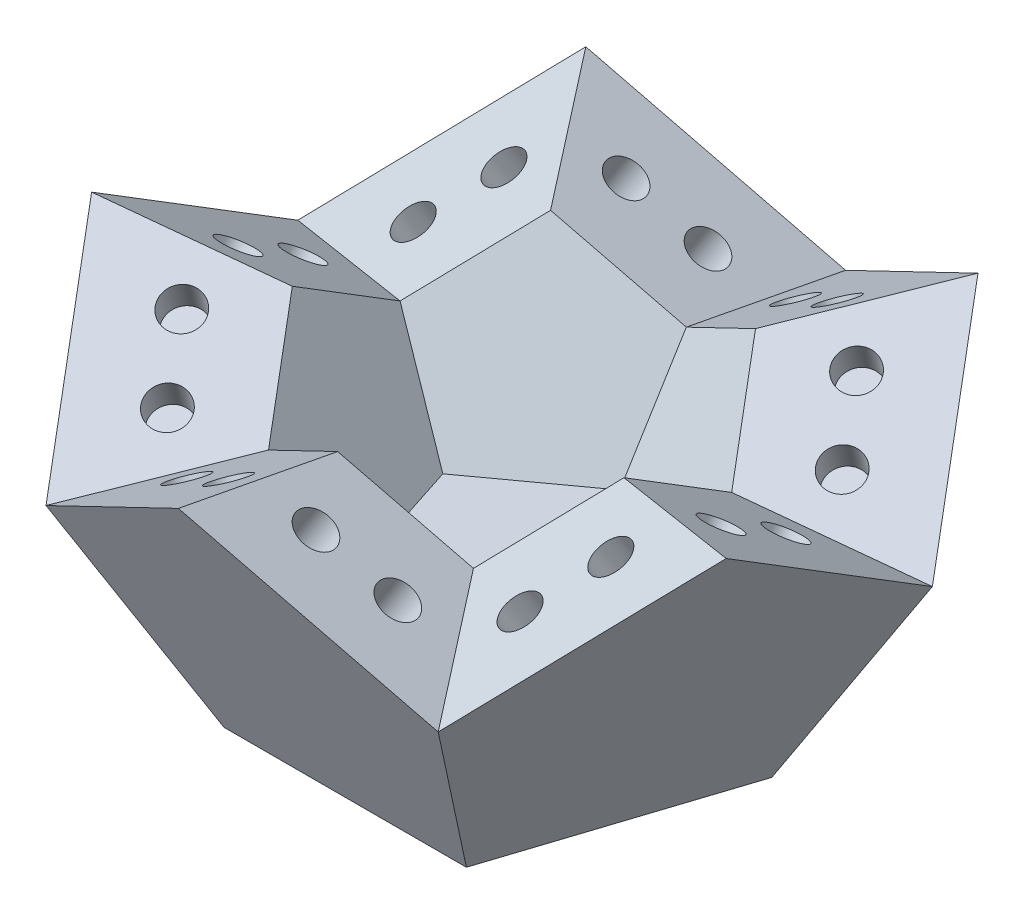
from build123d import *
from build123d.topology import SkipClean

# Parameters (mm, degrees)
BOSS_EXTRUDE1_DEPTH     = 6.752040791
BOSS_EXTRUDE1_TAPER     = 31.717474411
SKETCH3_R               = 1
CUT_EXTRUDE1_DEPTH      = 2
CIRPATTERN1_COUNT       = 5
MIRROR1_COPY_1_SKETCH_R = 1
MIRROR1_COPY_1_DEPTH    = 2
MIRROR1_COPY_2_SKETCH_R = 1
MIRROR1_COPY_2_DEPTH    = 2
MIRROR1_COPY_3_SKETCH_R = 1
MIRROR1_COPY_3_DEPTH    = 2
MIRROR1_COPY_4_SKETCH_R = 1
MIRROR1_COPY_4_DEPTH    = 2
MIRROR2_COPY_1_SKETCH_R = 1
MIRROR2_COPY_1_DEPTH    = 2
MIRROR2_COPY_2_SKETCH_R = 1
MIRROR2_COPY_2_DEPTH    = 2
MIRROR2_COPY_3_SKETCH_R = 1
MIRROR2_COPY_3_DEPTH    = 2
MIRROR2_COPY_4_SKETCH_R = 1
MIRROR2_COPY_4_DEPTH    = 2
MIRROR3_COPY_1_SKETCH_R = 1
MIRROR3_COPY_1_DEPTH    = 2
MIRROR3_COPY_2_SKETCH_R = 1
MIRROR3_COPY_2_DEPTH    = 2
MIRROR3_COPY_3_SKETCH_R = 1
MIRROR3_COPY_3_DEPTH    = 2
MIRROR3_COPY_4_SKETCH_R = 1
MIRROR3_COPY_4_DEPTH    = 2
MIRROR4_COPY_1_SKETCH_R = 1
MIRROR4_COPY_1_DEPTH    = 2
MIRROR4_COPY_2_SKETCH_R = 1
MIRROR4_COPY_2_DEPTH    = 2
MIRROR4_COPY_3_SKETCH_R = 1
MIRROR4_COPY_3_DEPTH    = 2
MIRROR4_COPY_4_SKETCH_R = 1
MIRROR4_COPY_4_DEPTH    = 2
MIRROR5_COPY_1_SKETCH_R = 1
MIRROR5_COPY_1_DEPTH    = 2
MIRROR5_COPY_2_SKETCH_R = 1
MIRROR5_COPY_2_DEPTH    = 2
MIRROR5_COPY_3_SKETCH_R = 1
MIRROR5_COPY_3_DEPTH    = 2
MIRROR5_COPY_4_SKETCH_R = 1
MIRROR5_COPY_4_DEPTH    = 2


with BuildPart() as part:
    # Sketch1 → Boss-Extrude1 (new body)
    with BuildSketch(Plane(origin=(0, 0, 0), x_dir=(1, 0, 0), z_dir=(0, 1, 0))):
        Polygon((0, 10.803265266), (-10.274515829, 3.338392562), (-6.35, -8.740025195), (6.35, -8.740025195), (10.274515829, 3.338392562), align=None)
    boss_extrude1 = extrude(amount=BOSS_EXTRUDE1_DEPTH, taper=BOSS_EXTRUDE1_TAPER)

    # Sketch3 → Cut-Extrude1 (cut)
    with BuildSketch(Plane(origin=(0, 3.908658092, 6.324341644), x_dir=(1, 0, 0), z_dir=(1.6266940928737823e-15, 0.5257311121191348, 0.8506508083520392))):
        with Locations((-2, -0.626153166)):
            Circle(SKETCH3_R)
        with Locations((2, -0.626153166)):
            Circle(SKETCH3_R)
    cut_extrude1 = extrude(amount=-CUT_EXTRUDE1_DEPTH, mode=Mode.SUBTRACT)

    # CirPattern1: Cut-Extrude1 ×5 about axis
    cirpattern1_axis = Axis((0, 14.848740719, 0), (0, -1, 0))
    for i in range(1, CIRPATTERN1_COUNT):
        add(cut_extrude1.rotate(cirpattern1_axis, i * 360 / CIRPATTERN1_COUNT), mode=Mode.SUBTRACT)

    # Mirror1: Boss-Extrude1, Cut-Extrude1 across plane
    add(boss_extrude1.mirror(Plane(origin=(0, 0, -10.803265266), x_dir=(-0.4742680099309791, 0.49867489660708403, 0.7255296012224607), z_dir=(-0.5000000000000008, 0.5257311121191346, -0.6881909602355855))))
    add(cut_extrude1.mirror(Plane(origin=(0, 0, -10.803265266), x_dir=(-0.4742680099309791, 0.49867489660708403, 0.7255296012224607), z_dir=(-0.5000000000000008, 0.5257311121191346, -0.6881909602355855))), mode=Mode.SUBTRACT)

    # Mirror1 copy 1 sketch → Mirror1 copy 1 (cut)
    with BuildSketch(Plane(origin=(-9.73216108, 7.817316184, -3.162170822), x_dir=(-0.4999999999999997, 0.8506508083520404, -0.16245984811645123), z_dir=(-0.30901699437494484, 0, 0.9510565162951544))):
        with Locations((-2, 0.626153166)):
            Circle(MIRROR1_COPY_1_SKETCH_R)
        with Locations((2, 0.626153166)):
            Circle(MIRROR1_COPY_1_SKETCH_R)
    extrude(amount=-MIRROR1_COPY_1_DEPTH, mode=Mode.SUBTRACT)

    # Mirror1 copy 2 sketch → Mirror1 copy 2 (cut)
    with BuildSketch(Plane(origin=(-3.717354749, 3.908658092, -5.116499868), x_dir=(-0.8090169943749469, 0, 0.587785252292474), z_dir=(0.5000000000000007, -0.5257311121191344, 0.6881909602355858))):
        with Locations((-2, 0.626153166)):
            Circle(MIRROR1_COPY_2_SKETCH_R)
        with Locations((2, 0.626153166)):
            Circle(MIRROR1_COPY_2_SKETCH_R)
    extrude(amount=-MIRROR1_COPY_2_DEPTH, mode=Mode.SUBTRACT)

    # Mirror1 copy 3 sketch → Mirror1 copy 3 (cut)
    with BuildSketch(Plane(origin=(0, 7.817316184, -10.232999736), x_dir=(0, -0.8506508083520413, 0.5257311121191314), z_dir=(1, 0, 0))):
        with Locations((-2, 0.626153166)):
            Circle(MIRROR1_COPY_3_SKETCH_R)
        with Locations((2, 0.626153166)):
            Circle(MIRROR1_COPY_3_SKETCH_R)
    extrude(amount=-MIRROR1_COPY_3_DEPTH, mode=Mode.SUBTRACT)

    # Mirror1 copy 4 sketch → Mirror1 copy 4 (cut)
    with BuildSketch(Plane(origin=(-3.717354749, 14.141657828, -11.440841512), x_dir=(0.809016994374946, -0.5257311121191345, -0.2628655560595698), z_dir=(0.5000000000000017, 0.8506508083520392, -0.16245984811645123))):
        with Locations((-2, 0.626153166)):
            Circle(MIRROR1_COPY_4_SKETCH_R)
        with Locations((2, 0.626153166)):
            Circle(MIRROR1_COPY_4_SKETCH_R)
    extrude(amount=-MIRROR1_COPY_4_DEPTH, mode=Mode.SUBTRACT)

    # Mirror2: Boss-Extrude1, Cut-Extrude1 across plane
    add(boss_extrude1.mirror(Plane(origin=(-10.274515829, 0, -3.338392562), x_dir=(0.22041412184245582, -0.14323377902898754, 0.9648324722134378), z_dir=(-0.8090169943749466, 0.5257311121191346, 0.2628655560595678))))
    add(cut_extrude1.mirror(Plane(origin=(-10.274515829, 0, -3.338392562), x_dir=(0.22041412184245582, -0.14323377902898754, 0.9648324722134378), z_dir=(-0.8090169943749466, 0.5257311121191346, 0.2628655560595678))), mode=Mode.SUBTRACT)

    # Mirror2 copy 1 sketch → Mirror2 copy 1 (cut)
    with BuildSketch(Plane(origin=(-6.014806331, 3.908658092, 1.954329046), x_dir=(0.309016994374948, 0, 0.9510565162951534), z_dir=(0.8090169943749471, -0.5257311121191345, -0.26286555605956746))):
        with Locations((-2, 0.626153166)):
            Circle(MIRROR2_COPY_1_SKETCH_R)
        with Locations((2, 0.626153166)):
            Circle(MIRROR2_COPY_1_SKETCH_R)
    extrude(amount=-MIRROR2_COPY_1_DEPTH, mode=Mode.SUBTRACT)

    # Mirror2 copy 2 sketch → Mirror2 copy 2 (cut)
    with BuildSketch(Plane(origin=(-9.73216108, 7.817316184, -3.162170822), x_dir=(0.4999999999999979, -0.8506508083520414, 0.16245984811645336), z_dir=(0.3090169943749476, -1.1061928888882846e-15, -0.9510565162951538))):
        with Locations((-2, 0.626153166)):
            Circle(MIRROR2_COPY_2_SKETCH_R)
        with Locations((2, 0.626153166)):
            Circle(MIRROR2_COPY_2_SKETCH_R)
    extrude(amount=-MIRROR2_COPY_2_DEPTH, mode=Mode.SUBTRACT)

    # Mirror2 copy 3 sketch → Mirror2 copy 3 (cut)
    with BuildSketch(Plane(origin=(-12.029612663, 14.141657828, 0), x_dir=(-2.8865798640254106e-15, -0.5257311121191347, -0.8506508083520393), z_dir=(2.4424906541753397e-15, 0.8506508083520393, -0.5257311121191347))):
        with Locations((-2, 0.626153166)):
            Circle(MIRROR2_COPY_3_SKETCH_R)
        with Locations((2, 0.626153166)):
            Circle(MIRROR2_COPY_3_SKETCH_R)
    extrude(amount=-MIRROR2_COPY_3_DEPTH, mode=Mode.SUBTRACT)

    # Mirror2 copy 4 sketch → Mirror2 copy 4 (cut)
    with BuildSketch(Plane(origin=(-9.73216108, 14.141657828, 7.070828914), x_dir=(-0.5000000000000008, 0.5257311121191339, -0.6881909602355862), z_dir=(0.30901699437495067, 0.85065080835204, 0.4253254041760177))):
        with Locations((-2, 0.626153166)):
            Circle(MIRROR2_COPY_4_SKETCH_R)
        with Locations((2, 0.626153166)):
            Circle(MIRROR2_COPY_4_SKETCH_R)
    extrude(amount=-MIRROR2_COPY_4_DEPTH, mode=Mode.SUBTRACT)

    # Mirror3: Boss-Extrude1, Cut-Extrude1 across plane
    add(boss_extrude1.mirror(Plane(origin=(-6.35, 0, 8.740025195), x_dir=(-2.6320463315684497e-15, -0.8506508083520393, 0.5257311121191345), z_dir=(1.6266940928737817e-15, 0.5257311121191347, 0.8506508083520393))))
    add(cut_extrude1.mirror(Plane(origin=(-6.35, 0, 8.740025195), x_dir=(-2.6320463315684497e-15, -0.8506508083520393, 0.5257311121191345), z_dir=(1.6266940928737817e-15, 0.5257311121191347, 0.8506508083520393))), mode=Mode.SUBTRACT)

    # Mirror3 copy 1 sketch → Mirror3 copy 1 (cut)
    with SkipClean():  # the faces are left unmerged after this step: merging them gives an invalid solid
        with BuildSketch(Plane(origin=(-6.014806331, 7.817316184, 8.27867069), x_dir=(0.3090169943749462, -0.8506508083520415, -0.4253254041760179), z_dir=(-0.8090169943749479, 0, -0.5877852522924727))):
            with Locations((-2, 0.626153166)):
                Circle(MIRROR3_COPY_1_SKETCH_R)
            with Locations((2, 0.626153166)):
                Circle(MIRROR3_COPY_1_SKETCH_R)
        extrude(amount=-MIRROR3_COPY_1_DEPTH, mode=Mode.SUBTRACT)

    # Mirror3 copy 2 sketch → Mirror3 copy 2 (cut)
    with SkipClean():  # the faces are left unmerged after this step: merging them gives an invalid solid
        with BuildSketch(Plane(origin=(-3.717354749, 14.141657828, 11.440841512), x_dir=(-0.8090169943749482, -0.5257311121191344, -0.26286555605956313), z_dir=(-0.5, 0.8506508083520394, -0.1624598481164556))):
            with Locations((-2, 0.626153166)):
                Circle(MIRROR3_COPY_2_SKETCH_R)
            with Locations((2, 0.626153166)):
                Circle(MIRROR3_COPY_2_SKETCH_R)
        extrude(amount=-MIRROR3_COPY_2_DEPTH, mode=Mode.SUBTRACT)

    # Mirror3 copy 3 sketch → Mirror3 copy 3 (cut)
    with SkipClean():  # the faces are left unmerged after this step: merging them gives an invalid solid
        with BuildSketch(Plane(origin=(3.717354749, 14.141657828, 11.440841512), x_dir=(-0.8090169943749467, 0.5257311121191343, 0.262865556059568), z_dir=(0.4999999999999991, 0.8506508083520395, -0.16245984811645744))):
            with Locations((-2, 0.626153166)):
                Circle(MIRROR3_COPY_3_SKETCH_R)
            with Locations((2, 0.626153166)):
                Circle(MIRROR3_COPY_3_SKETCH_R)
        extrude(amount=-MIRROR3_COPY_3_DEPTH, mode=Mode.SUBTRACT)

    # Mirror3 copy 4 sketch → Mirror3 copy 4 (cut)
    with SkipClean():  # the faces are left unmerged after this step: merging them gives an invalid solid
        with BuildSketch(Plane(origin=(6.014806331, 7.817316184, 8.27867069), x_dir=(0.3090169943749485, 0.8506508083520405, 0.42532540417601816), z_dir=(0.8090169943749456, 0, -0.5877852522924757))):
            with Locations((-2, 0.626153166)):
                Circle(MIRROR3_COPY_4_SKETCH_R)
            with Locations((2, 0.626153166)):
                Circle(MIRROR3_COPY_4_SKETCH_R)
        extrude(amount=-MIRROR3_COPY_4_DEPTH, mode=Mode.SUBTRACT)

    # Mirror4: Boss-Extrude1, Cut-Extrude1 across plane
    with SkipClean():  # the faces are left unmerged after this step: merging them gives an invalid solid
        add(boss_extrude1.mirror(Plane(origin=(6.35, 0, 8.740025195), x_dir=(-0.22041412184245382, -0.1432337790289861, 0.9648324722134385), z_dir=(0.8090169943749472, 0.5257311121191346, 0.26286555605956535))))
        add(cut_extrude1.mirror(Plane(origin=(6.35, 0, 8.740025195), x_dir=(-0.22041412184245382, -0.1432337790289861, 0.9648324722134385), z_dir=(0.8090169943749472, 0.5257311121191346, 0.26286555605956535))), mode=Mode.SUBTRACT)

    # Mirror4 copy 1 sketch → Mirror4 copy 1 (cut)
    with SkipClean():  # the faces are left unmerged after this step: merging them gives an invalid solid
        with BuildSketch(Plane(origin=(9.73216108, 14.141657828, 7.070828914), x_dir=(-0.49999999999999695, -0.5257311121191344, 0.6881909602355882), z_dir=(-0.30901699437495, 0.8506508083520392, 0.4253254041760192))):
            with Locations((-2, 0.626153166)):
                Circle(MIRROR4_COPY_1_SKETCH_R)
            with Locations((2, 0.626153166)):
                Circle(MIRROR4_COPY_1_SKETCH_R)
        extrude(amount=-MIRROR4_COPY_1_DEPTH, mode=Mode.SUBTRACT)

    # Mirror4 copy 2 sketch → Mirror4 copy 2 (cut)
    with SkipClean():  # the faces are left unmerged after this step: merging them gives an invalid solid
        with BuildSketch(Plane(origin=(12.029612663, 14.141657828, 0), x_dir=(0, 0.5257311121191339, 0.8506508083520398), z_dir=(-4.1633363423443354e-15, 0.8506508083520398, -0.5257311121191338))):
            with Locations((-2, 0.626153166)):
                Circle(MIRROR4_COPY_2_SKETCH_R)
            with Locations((2, 0.626153166)):
                Circle(MIRROR4_COPY_2_SKETCH_R)
        extrude(amount=-MIRROR4_COPY_2_DEPTH, mode=Mode.SUBTRACT)

    # Mirror4 copy 3 sketch → Mirror4 copy 3 (cut)
    with SkipClean():  # the faces are left unmerged after this step: merging them gives an invalid solid
        with BuildSketch(Plane(origin=(9.73216108, 7.817316184, -3.162170822), x_dir=(0.4999999999999985, 0.8506508083520405, -0.1624598481164543), z_dir=(-0.3090169943749497, 0, -0.9510565162951529))):
            with Locations((-2, 0.626153166)):
                Circle(MIRROR4_COPY_3_SKETCH_R)
            with Locations((2, 0.626153166)):
                Circle(MIRROR4_COPY_3_SKETCH_R)
        extrude(amount=-MIRROR4_COPY_3_DEPTH, mode=Mode.SUBTRACT)

    # Mirror4 copy 4 sketch → Mirror4 copy 4 (cut)
    with SkipClean():  # the faces are left unmerged after this step: merging them gives an invalid solid
        with BuildSketch(Plane(origin=(6.014806331, 3.908658092, 1.954329046), x_dir=(0.3090169943749467, 0, -0.9510565162951539), z_dir=(-0.8090169943749471, -0.5257311121191344, -0.2628655560595658))):
            with Locations((-2, 0.626153166)):
                Circle(MIRROR4_COPY_4_SKETCH_R)
            with Locations((2, 0.626153166)):
                Circle(MIRROR4_COPY_4_SKETCH_R)
        extrude(amount=-MIRROR4_COPY_4_DEPTH, mode=Mode.SUBTRACT)

    # Mirror5: Boss-Extrude1, Cut-Extrude1 across plane
    with SkipClean():  # the faces are left unmerged after this step: merging them gives an invalid solid
        add(boss_extrude1.mirror(Plane(origin=(10.274515829, 0, -3.338392562), x_dir=(0.4742680099309791, 0.49867489660708614, 0.7255296012224591), z_dir=(0.4999999999999987, 0.5257311121191346, -0.688190960235587))))
        add(cut_extrude1.mirror(Plane(origin=(10.274515829, 0, -3.338392562), x_dir=(0.4742680099309791, 0.49867489660708614, 0.7255296012224591), z_dir=(0.4999999999999987, 0.5257311121191346, -0.688190960235587))), mode=Mode.SUBTRACT)

    # Mirror5 copy 1 sketch → Mirror5 copy 1 (cut)
    with SkipClean():  # the faces are left unmerged after this step: merging them gives an invalid solid
        with BuildSketch(Plane(origin=(3.717354749, 14.141657828, -11.440841512), x_dir=(0.8090169943749475, 0.5257311121191339, 0.26286555605956596), z_dir=(-0.5000000000000014, 0.8506508083520399, -0.16245984811644945))):
            with Locations((-2, 0.626153166)):
                Circle(MIRROR5_COPY_1_SKETCH_R)
            with Locations((2, 0.626153166)):
                Circle(MIRROR5_COPY_1_SKETCH_R)
        extrude(amount=-MIRROR5_COPY_1_DEPTH, mode=Mode.SUBTRACT)

    # Mirror5 copy 2 sketch → Mirror5 copy 2 (cut)
    with SkipClean():  # the faces are left unmerged after this step: merging them gives an invalid solid
        with BuildSketch(Plane(origin=(0, 7.817316184, -10.232999736), x_dir=(-1.2043746199203667e-15, 0.8506508083520407, -0.5257311121191327), z_dir=(-1, 0, 0))):
            with Locations((-2, 0.626153166)):
                Circle(MIRROR5_COPY_2_SKETCH_R)
            with Locations((2, 0.626153166)):
                Circle(MIRROR5_COPY_2_SKETCH_R)
        extrude(amount=-MIRROR5_COPY_2_DEPTH, mode=Mode.SUBTRACT)

    # Mirror5 copy 3 sketch → Mirror5 copy 3 (cut)
    with SkipClean():  # the faces are left unmerged after this step: merging them gives an invalid solid
        with BuildSketch(Plane(origin=(3.717354749, 3.908658092, -5.116499868), x_dir=(-0.8090169943749478, 0, -0.5877852522924727), z_dir=(-0.4999999999999993, -0.5257311121191345, 0.6881909602355869))):
            with Locations((-2, 0.626153166)):
                Circle(MIRROR5_COPY_3_SKETCH_R)
            with Locations((2, 0.626153166)):
                Circle(MIRROR5_COPY_3_SKETCH_R)
        extrude(amount=-MIRROR5_COPY_3_DEPTH, mode=Mode.SUBTRACT)

    # Mirror5 copy 4 sketch → Mirror5 copy 4 (cut)
    with SkipClean():  # the faces are left unmerged after this step: merging them gives an invalid solid
        with BuildSketch(Plane(origin=(9.73216108, 7.817316184, -3.162170822), x_dir=(-0.4999999999999984, -0.8506508083520413, 0.1624598481164517), z_dir=(0.3090169943749473, -1.1894596157351711e-15, 0.9510565162951536))):
            with Locations((-2, 0.626153166)):
                Circle(MIRROR5_COPY_4_SKETCH_R)
            with Locations((2, 0.626153166)):
                Circle(MIRROR5_COPY_4_SKETCH_R)
        extrude(amount=-MIRROR5_COPY_4_DEPTH, mode=Mode.SUBTRACT)


solid = part.part
